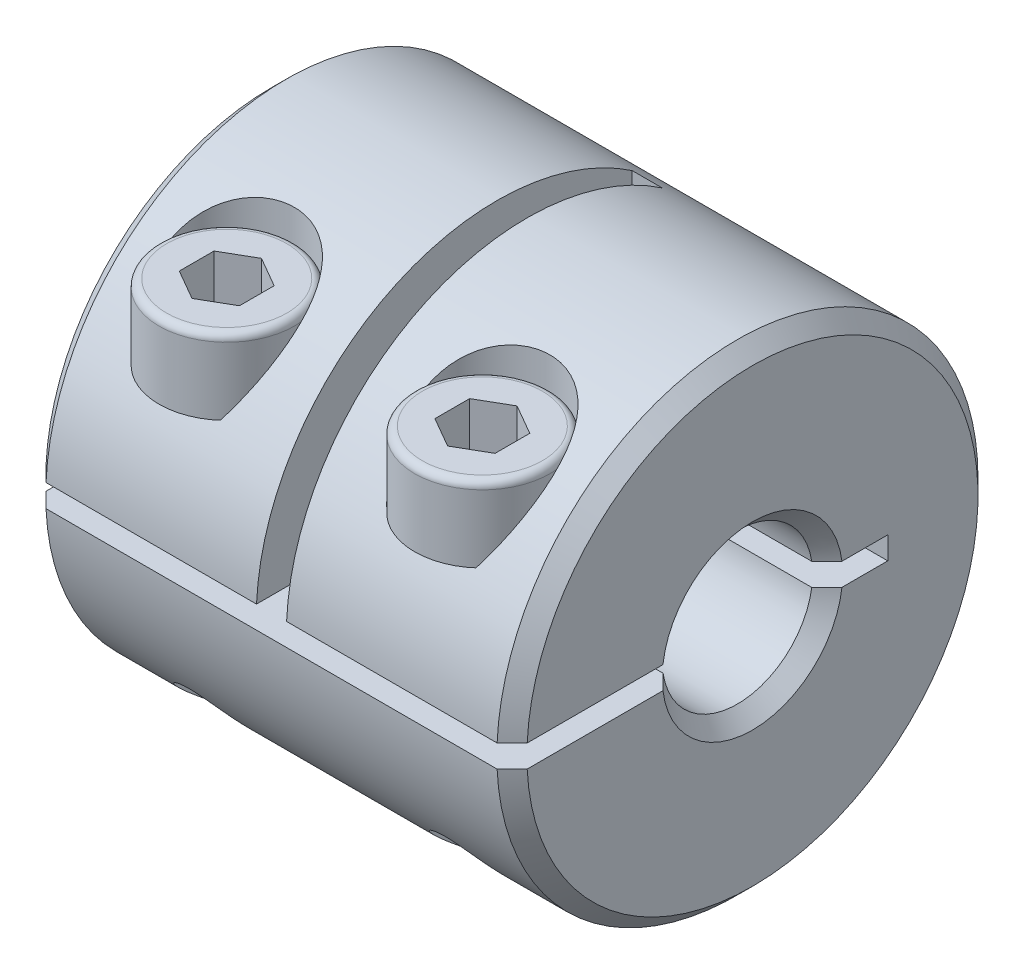
from build123d import *

# Parameters (mm, degrees)
SKETCH1_R           = 8
BOSS_EXTRUDE1_DEPTH = 8
SKETCH2_R           = 2.5
CUT_EXTRUDE1_DEPTH  = 17
CUT_EXTRUDE2_DEPTH  = 17
SKETCH6_W           = 1
SKETCH6_H           = 8.375
CUT_EXTRUDE3_DEPTH  = 13.491206104
CUT_EXTRUDE4_START  = -8.625
SKETCH7_R           = 1.25
CUT_EXTRUDE4_DEPTH  = 18
SKETCH8_R           = 2.25
CUT_EXTRUDE5_DEPTH  = 5.0000001
SKETCH9_R           = 2.25
BOSS_EXTRUDE2_DEPTH = 2.5
SKETCH10_R          = 1.25
BOSS_EXTRUDE3_DEPTH = 10.5
FILLET1_R           = 0.25
CUT_EXTRUDE6_DEPTH  = 2
CHAMFER1_SIZE       = 0.5


with BuildPart() as part:
    # Sketch1 → Boss-Extrude1 (new body, symmetric)
    with BuildSketch(Plane(origin=(0, 0, 0), x_dir=(0, 0, -1), z_dir=(1, 0, 0))):
        Circle(SKETCH1_R)
    extrude(amount=BOSS_EXTRUDE1_DEPTH, both=True)

    # Sketch2 → Cut-Extrude1 (cut, through all)
    with BuildSketch(Plane(origin=(8, 0, 0), x_dir=(0, 0, -1), z_dir=(1, 0, 0))):
        Circle(SKETCH2_R)
    extrude(amount=-CUT_EXTRUDE1_DEPTH, mode=Mode.SUBTRACT)

    # Sketch5 → Cut-Extrude2 (cut, through all)
    with BuildSketch(Plane(origin=(8, 0, 0), x_dir=(0, 0, -1), z_dir=(1, 0, 0))):
        with BuildLine():
            Line((-7.991206104, 0.375), (4.5, 0.375))
            Line((4.5, 0.375), (4.5, -0.375))
            Line((4.5, -0.375), (-7.991206104, -0.375))
            ThreePointArc((-7.991206104, -0.375), (-8, 0), (-7.991206104, 0.375))
        make_face()
    extrude(amount=-CUT_EXTRUDE2_DEPTH, mode=Mode.SUBTRACT)

    # Sketch6 → Cut-Extrude3 (cut, through all)
    with BuildSketch(Plane.XY.offset(-4.5)):
        with Locations((0, 3.8125)):
            Rectangle(SKETCH6_W, SKETCH6_H)
    extrude(amount=CUT_EXTRUDE3_DEPTH, mode=Mode.SUBTRACT)

    # Sketch7 → Cut-Extrude4 (cut)
    with BuildSketch(Plane(origin=(0, -0.375, 0), x_dir=(1, 0, 0), z_dir=(0, 1, 0)).offset(CUT_EXTRUDE4_START)):
        with Locations(Location((4.25, -5.231460548, 0), (0, 0, 270))):  # turned: the seam where the file's is
            Circle(SKETCH7_R)
    cut_extrude4 = extrude(amount=CUT_EXTRUDE4_DEPTH, mode=Mode.SUBTRACT)

    # Sketch8 → Cut-Extrude5 (cut, through all)
    with BuildSketch(Plane(origin=(0, 4, 0), x_dir=(-1, 0, 0), z_dir=(0, 1, 0))):
        with Locations((-4.25, 5.231460548)):
            Circle(SKETCH8_R)
    cut_extrude5 = extrude(amount=CUT_EXTRUDE5_DEPTH, mode=Mode.SUBTRACT)

    # Mirror1: Cut-Extrude4, Cut-Extrude5 across plane
    add(cut_extrude4.mirror(Plane(origin=(0, 0, 0), x_dir=(0, 0, 1), z_dir=(1, 0, 0))), mode=Mode.SUBTRACT)
    add(cut_extrude5.mirror(Plane(origin=(0, 0, 0), x_dir=(0, 0, 1), z_dir=(1, 0, 0))), mode=Mode.SUBTRACT)

    # Chamfer1
    chamfer1_edges = [part.edges().sort_by_distance(p)[0] for p in [
        (-8, -2.5, 0),
        (8, -2.5, 0),
        (-8, 0, -8),
        (8, 0, -8),
        (-8, 2.5, 0),
        (8, 2.5, 0),
    ]]
    chamfer(chamfer1_edges, length=CHAMFER1_SIZE)


with BuildPart() as body_2:
    # Sketch9 → Boss-Extrude2 (new body)
    with BuildSketch(Plane(origin=(0, 4, 0), x_dir=(1, 0, 0), z_dir=(0, 1, 0))):
        with Locations(Location((4.25, -5.231460548, 0), (0, 0, 270))):  # turned: the seam where the file's is
            Circle(SKETCH9_R)
    extrude(amount=BOSS_EXTRUDE2_DEPTH)

    # Sketch10 → Boss-Extrude3 (add)
    with BuildSketch(Plane(origin=(0, 6.5, 0), x_dir=(1, 0, 0), z_dir=(0, 1, 0))):
        with Locations(Location((4.25, -5.231460548, 0), (0, 0, 270))):  # turned: the seam where the file's is
            Circle(SKETCH10_R)
    extrude(amount=-BOSS_EXTRUDE3_DEPTH)

    # Fillet1
    fillet1_edges = [body_2.edges().sort_by_distance(p)[0] for p in [
        (4.25, 6.5, 2.981460548),
        (4.25, -4, 3.981460548),
    ]]
    fillet(fillet1_edges, radius=FILLET1_R)

    # Sketch11 → Cut-Extrude6 (cut)
    with BuildSketch(Plane(origin=(0, 6.5, 0), x_dir=(1, 0, 0), z_dir=(0, 1, 0))):
        Polygon((4.25, -4.07676001), (3.25, -4.654110279), (3.25, -5.808810817), (4.25, -6.386161086), (5.25, -5.808810817), (5.25, -4.654110279), align=None)
    extrude(amount=-CUT_EXTRUDE6_DEPTH, mode=Mode.SUBTRACT)


with BuildPart() as body_3:
    # Mirror2: mirrored copy
    add(body_2.part.mirror(Plane(origin=(0, 0, 0), x_dir=(0, 0, 1), z_dir=(1, 0, 0))))


solid = Compound([part.part, body_2.part, body_3.part])
